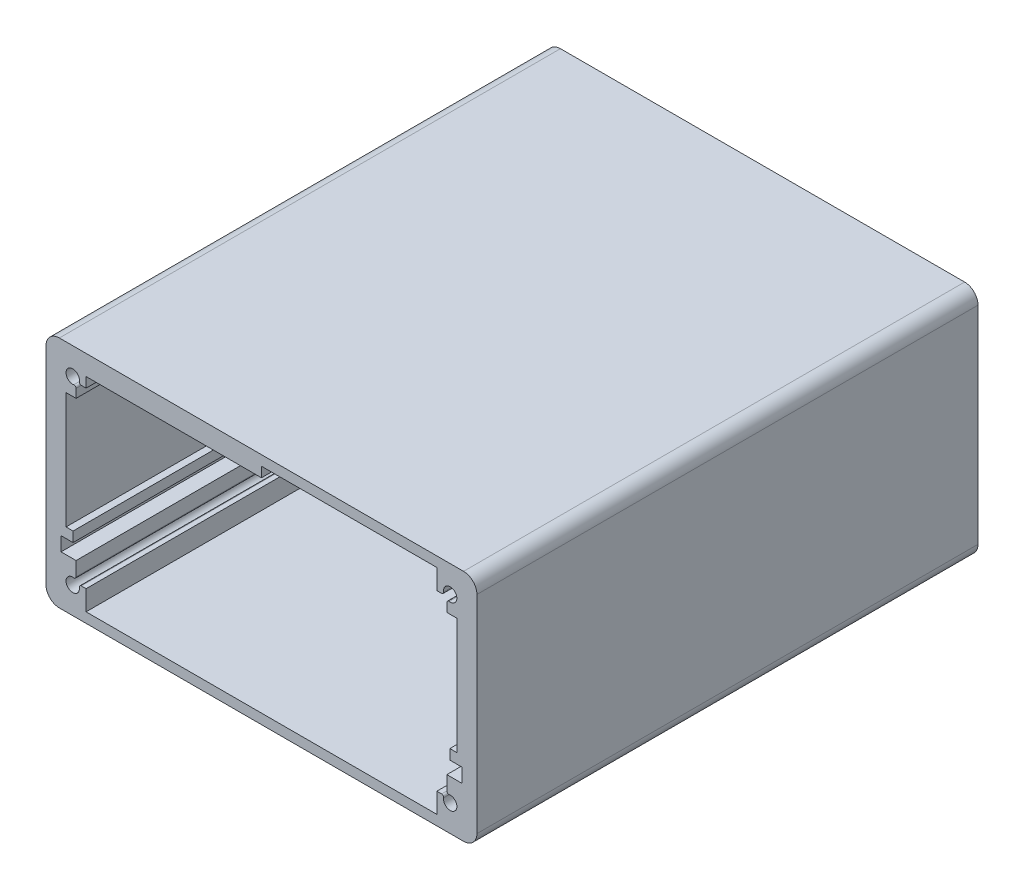
from build123d import *

# Parameters (mm, degrees)
SKETCH1_W           = 64.5
SKETCH1_H           = 35
BOSS_EXTRUDE1_DEPTH = 75
FILLET1_R           = 2
SKETCH2_R           = 1
FIX_2_DEPTH         = 84.494386039
CUT_EXTRUDE2_DEPTH  = 75
CUT_EXTRUDE3_DEPTH  = 75
SKETCH5_W           = 26.25
SKETCH5_H           = 1.5
CUT_EXTRUDE4_DEPTH  = 75
FILLET2_R           = 0.3
SKETCH6_W           = 52.5
SKETCH6_H           = 1.5
BAS_DEPTH           = 84.494386039


with BuildPart() as part:
    # Sketch1 → Boss-Extrude1 (new body)
    with BuildSketch(Plane.XY):
        Rectangle(SKETCH1_W, SKETCH1_H)
    extrude(amount=BOSS_EXTRUDE1_DEPTH)

    # Fillet1
    fillet1_edges = [part.edges().sort_by_distance(p)[0] for p in [
        (-32.25, -17.5, 37.5),
        (32.25, -17.5, 37.5),
        (32.25, 17.5, 37.5),
        (-32.25, 17.5, 37.5),
    ]]
    fillet(fillet1_edges, radius=FILLET1_R)

    # Sketch2 → fix 2 (cut, through all)
    with BuildSketch(Plane.XY.offset(75)):
        with Locations((-28.25, 13.5)):
            Circle(SKETCH2_R)
        with Locations((-28.25, -13.5)):
            Circle(SKETCH2_R)
        with Locations((28.25, -13.5)):
            Circle(SKETCH2_R)
        with Locations((28.25, 13.5)):
            Circle(SKETCH2_R)
    extrude(amount=-FIX_2_DEPTH, mode=Mode.SUBTRACT)

    # Sketch3 → Cut-Extrude2 (cut)
    with BuildSketch(Plane.XY.offset(75)):
        Polygon((-27.75, 10.92), (-27.75, 13), (-26.25, 13), (-26.25, 14.5), (0, 14.5), (26.25, 14.5), (26.25, 13), (27.75, 13), (27.75, 10.92), (29.25, 10.92), (29.25, -6.5), (27.75, -6.5), (27.75, -13), (26.25, -13), (26.25, -14.5), (0, -14.5), (-26.25, -14.5), (-26.25, -13), (-27.75, -13), (-27.75, -6.5), (-29.25, -6.5), (-29.25, 10.92), align=None)
    extrude(amount=-CUT_EXTRUDE2_DEPTH, mode=Mode.SUBTRACT)

    # Sketch4 → Cut-Extrude3 (cut)
    with BuildSketch(Plane.XY.offset(75)):
        Polygon((-30, -8), (-28.2, -8), (-28.2, -4.99063684), (28.2, -5.371209777), (28.2, -8), (30, -8), (30, -10.1), (-30, -10.1), align=None)
    extrude(amount=-CUT_EXTRUDE3_DEPTH, mode=Mode.SUBTRACT)

    # Sketch5 → Cut-Extrude4 (cut)
    with BuildSketch(Plane.XY.offset(75)):
        with Locations((13.125, 15.25)):
            Rectangle(SKETCH5_W, SKETCH5_H)
    extrude(amount=-CUT_EXTRUDE4_DEPTH, mode=Mode.SUBTRACT)

    # Fillet2
    fillet2_edges = [part.edges().sort_by_distance(p)[0] for p in [
        (27.383974596, 13, 37.5),
        (27.75, 12.633974596, 37.5),
        (-27.383974596, 13, 37.5),
        (-27.75, 12.633974596, 37.5),
        (-27.75, -12.633974596, 37.5),
        (-27.383974596, -13, 37.5),
        (27.383974596, -13, 37.5),
        (27.75, -12.633974596, 37.5),
    ]]
    fillet(fillet2_edges, radius=FILLET2_R)

    # Sketch6 → bas (cut, through all)
    with BuildSketch(Plane.XY.offset(75)):
        with Locations((0, -15.25)):
            Rectangle(SKETCH6_W, SKETCH6_H)
    extrude(amount=-BAS_DEPTH, mode=Mode.SUBTRACT)


solid = part.part
